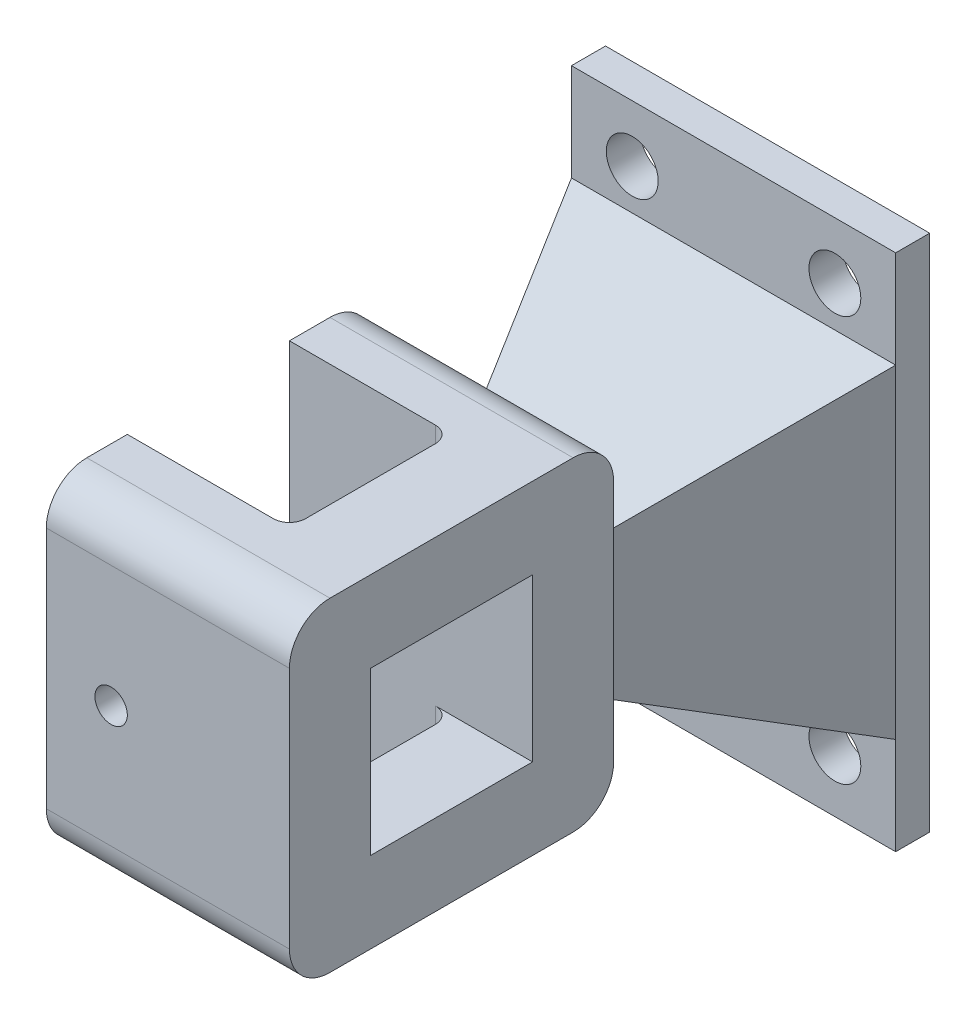
from build123d import *

# Parameters (mm, degrees)
SKETCH_1_W           = 40
SKETCH_1_H           = 64
SKETCH_1_R           = 3.2
EXTRUDE_1_DEPTH      = 4.2
SKETCH_2_R           = 16
SKETCH_2_W           = 20
SKETCH_2_H           = 20
EXTRUDE_2_DEPTH      = 10
EXTRUDE_2_DEPTH_BACK = 20
SKETCH_3_W           = 20
SKETCH_3_H           = 32
CUT_EXTRUDE_1_DEPTH  = 20
EXTRUDE_3_DEPTH      = 3
SKETCH_7_W           = 14
SKETCH_7_H           = 6
EXTRUDE_4_DEPTH      = 0.283766
EXTRUDE_5_DEPTH      = 3
SKETCH_9_W           = 6
SKETCH_9_H           = 14
EXTRUDE_6_DEPTH      = 1.612505
SKETCH_10_W          = 40
SKETCH_10_H          = 40
SKETCH_11_W          = 14
SKETCH_11_H          = 14
SKETCH_12_W          = 14
SKETCH_12_H          = 14
EXTRUDE_8_DEPTH      = 6
SKETCH_14_W          = 40
SKETCH_14_H          = 40
SKETCH_14_W_2        = 20
SKETCH_14_H_2        = 20
EXTRUDE_10_DEPTH     = 10
SKETCH_15_W          = 10
SKETCH_15_H          = 40
EXTRUDE_11_DEPTH     = 20
CUT_EXTRUDE_START    = -10
SKETCH_4_R           = 2
CUT_EXTRUDE_2_DEPTH  = 40
FILLET_2_R           = 5
FILLET_3_R           = 2


with BuildPart() as part:
    # 스케치1 → 보스-돌출1 (new body)
    with BuildSketch(Plane.XY):
        Rectangle(SKETCH_1_W, SKETCH_1_H)
        with Locations((-12.5, 25)):
            Circle(SKETCH_1_R, mode=Mode.SUBTRACT)
        with Locations((12.5, 25)):
            Circle(SKETCH_1_R, mode=Mode.SUBTRACT)
        with Locations((12.5, -25)):
            Circle(SKETCH_1_R, mode=Mode.SUBTRACT)
        with Locations((-12.5, -25)):
            Circle(SKETCH_1_R, mode=Mode.SUBTRACT)
    extrude(amount=EXTRUDE_1_DEPTH)

    # 스케치5 → 보스-돌출3 (add, symmetric)
    with BuildSketch(Plane(origin=(0, 0, 0), x_dir=(1, 0, 0), z_dir=(0, 1, 0))):
        Polygon((-20, -4.2), (-7, -33), (7, -33), (20, -4.2), align=None)
        Polygon((-13.805819277, -8.2), (-4, -8.2), (-4, -29.923661167), align=None, mode=Mode.SUBTRACT)
        Polygon((4, -29.923661167), (13.805819277, -8.2), (4, -8.2), align=None, mode=Mode.SUBTRACT)
    extrude(amount=EXTRUDE_3_DEPTH, both=True)



with BuildPart() as body_2:
    # 스케치2 → 보스-돌출2 (new body, two sides)
    with BuildSketch(Plane(origin=(0, 0, 0), x_dir=(0, 0, -1), z_dir=(1, 0, 0))) as extrude_2_sk:
        with Locations((-49, 0)):
            Circle(SKETCH_2_R)
        with Locations((-49, 0)):
            Rectangle(SKETCH_2_W, SKETCH_2_H, mode=Mode.SUBTRACT)
    extrude(amount=EXTRUDE_2_DEPTH)
    extrude(extrude_2_sk.sketch, amount=-EXTRUDE_2_DEPTH_BACK)

    # 스케치3 → 컷-돌출1 (cut)
    with BuildSketch(Plane.ZY.offset(20)):
        with Locations((49, 0)):
            Rectangle(SKETCH_3_W, SKETCH_3_H)
    extrude(amount=-CUT_EXTRUDE_1_DEPTH, mode=Mode.SUBTRACT)


with BuildPart() as part_1:
    add(part.part)

    add(body_2.part)  # 보스-돌출4 merges body 2
    # 스케치7 → 보스-돌출4 (add)
    with BuildSketch(Plane.XY.offset(33)):
        Rectangle(SKETCH_7_W, SKETCH_7_H)
    extrude(amount=EXTRUDE_4_DEPTH)

    # 스케치8 → 보스-돌출5 (add, symmetric)
    with BuildSketch(Plane(origin=(0, 0, 0), x_dir=(0, 0, -1), z_dir=(1, 0, 0))):
        Polygon((-4.2, 20), (-33, 7), (-33, -7), (-4.2, -20), align=None)
        Polygon((-8.2, 13.805819277), (-8.2, 4), (-29.923661167, 4), align=None, mode=Mode.SUBTRACT)
        Polygon((-8.2, -4), (-29.923661167, -4), (-8.2, -13.805819277), align=None, mode=Mode.SUBTRACT)
    extrude(amount=EXTRUDE_5_DEPTH, both=True)

    # 스케치9 → 보스-돌출6 (add)
    with BuildSketch(Plane.XY.offset(33)):
        Rectangle(SKETCH_9_W, SKETCH_9_H)
    extrude(amount=EXTRUDE_6_DEPTH)

    # 스케치10 → 로프트1 section 0
    with BuildSketch(Plane.XY.offset(4.2)):
        Rectangle(SKETCH_10_W, SKETCH_10_H)
    # 스케치11 → 로프트1 section 1
    with BuildSketch(Plane.XY.offset(33)):
        Rectangle(SKETCH_11_W, SKETCH_11_H)
    loft()

    # 스케치12 → 보스-돌출8 (add)
    with BuildSketch(Plane.XY.offset(33)):
        Rectangle(SKETCH_12_W, SKETCH_12_H)
    extrude(amount=EXTRUDE_8_DEPTH)

    # 스케치14 → 보스-돌출10 (add)
    with BuildSketch(Plane(origin=(10, 0, 0), x_dir=(0, 0, -1), z_dir=(1, 0, 0))):
        with Locations((-49, 0)):
            Rectangle(SKETCH_14_W, SKETCH_14_H)
        with Locations((-49, 0)):
            Rectangle(SKETCH_14_W_2, SKETCH_14_H_2, mode=Mode.SUBTRACT)
    extrude(amount=-EXTRUDE_10_DEPTH)

    # 스케치15 → 보스-돌출11 (add)
    with BuildSketch(Plane.ZY.offset(20)):
        with Locations((64, 0)):
            Rectangle(SKETCH_15_W, SKETCH_15_H)
        with Locations((34, 0)):
            Rectangle(SKETCH_15_W, SKETCH_15_H)
    extrude(amount=-EXTRUDE_11_DEPTH)

    # 스케치4 → 컷-돌출2 (cut)
    with BuildSketch(Plane.XY.offset(39).offset(CUT_EXTRUDE_START)):
        with Locations((-12, 0)):
            Circle(SKETCH_4_R)
    extrude(amount=CUT_EXTRUDE_2_DEPTH, mode=Mode.SUBTRACT)

    # 필렛2
    fillet_2_edges = [part_1.edges().sort_by_distance(p)[0] for p in [
        (-5, 20, 29),
        (-5, -20, 29),
        (-5, -20, 69),
        (-5, 20, 69),
    ]]
    fillet(fillet_2_edges, radius=FILLET_2_R)

    # 필렛3
    fillet_3_edges = [part_1.edges().sort_by_distance(p)[0] for p in [
        (0, 15, 39),
        (0, -15, 39),
        (0, 15, 59),
        (0, -15, 59),
    ]]
    fillet(fillet_3_edges, radius=FILLET_3_R)


solid = part_1.part
